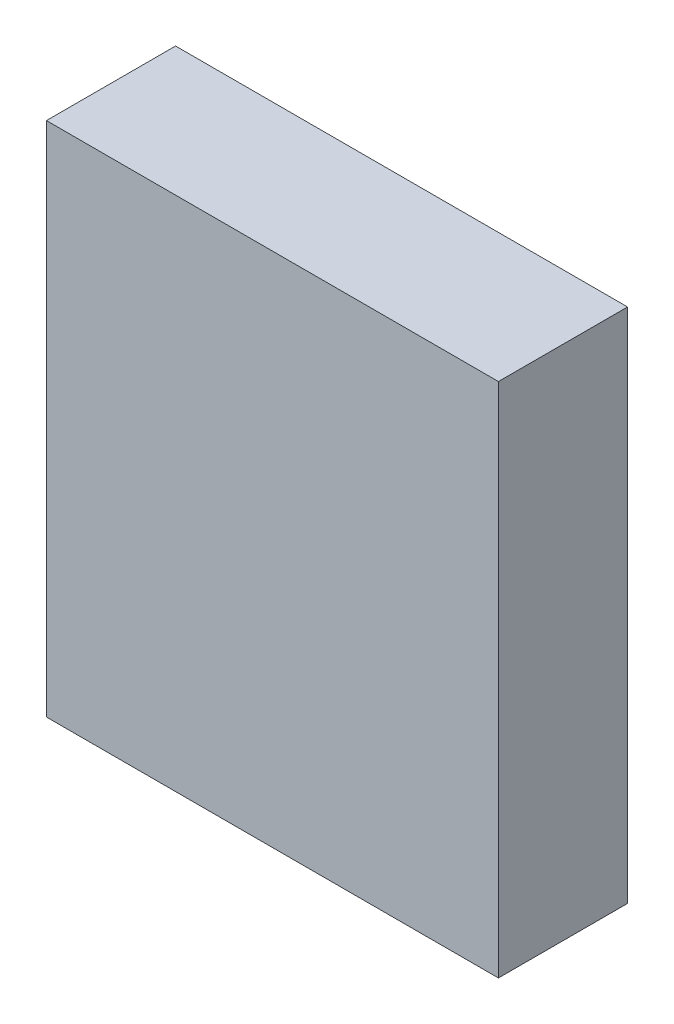
from build123d import *

# Parameters (mm, degrees)
SKETCH1_W           = 35
SKETCH1_H           = 10
BOSS_EXTRUDE1_DEPTH = 40


with BuildPart() as part:
    # Sketch1 → Boss-Extrude1 (new body)
    with BuildSketch(Plane(origin=(0, 0, 0), x_dir=(1, 0, 0), z_dir=(0, 1, 0))):
        with Locations((17.5, 5)):
            Rectangle(SKETCH1_W, SKETCH1_H)
    extrude(amount=BOSS_EXTRUDE1_DEPTH)


solid = part.part
